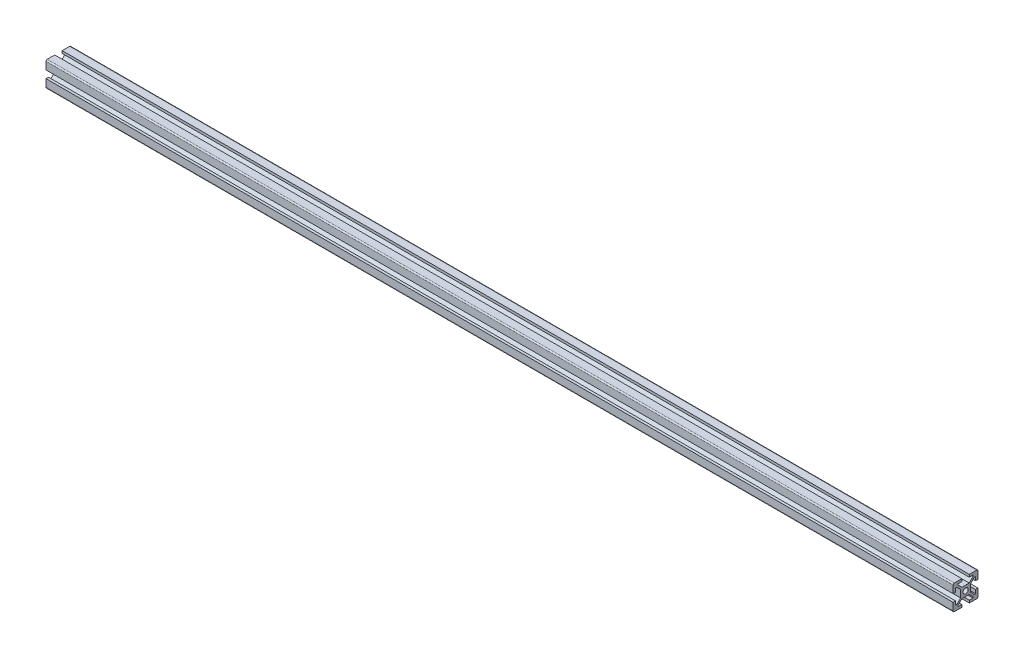
from build123d import *

# Parameters (mm, degrees)
SKETCH1_R           = 2.1
BOSS_EXTRUDE1_DEPTH = 730


with BuildPart() as part:
    # Sketch1 → Boss-Extrude1 (new body)
    with BuildSketch(Plane(origin=(0, 0, 0), x_dir=(0, 0, -1), z_dir=(1, 0, 0))):
        with BuildLine():
            Line((-10, 9), (-10, 3))
            Line((-10, 3), (-8, 3))
            Line((-8, 3), (-8, 6))
            Line((-8, 6), (-7.060660172, 6))
            Line((-7.060660172, 6), (-4, 2.939339828))
            Line((-4, 2.939339828), (-4, -2.939339828))
            Line((-4, -2.939339828), (-7.060660172, -6))
            Line((-7.060660172, -6), (-8, -6))
            Line((-8, -6), (-8, -3))
            Line((-8, -3), (-10, -3))
            Line((-10, -3), (-10, -9))
            ThreePointArc((-10, -9), (-9.707106781, -9.707106781), (-9, -10))
            Line((-9, -10), (-3, -10))
            Line((-3, -10), (-3, -8))
            Line((-3, -8), (-6, -8))
            Line((-6, -8), (-6, -7.060660172))
            Line((-6, -7.060660172), (-2.939339828, -4))
            Line((-2.939339828, -4), (2.939339828, -4))
            Line((2.939339828, -4), (6, -7.060660172))
            Line((6, -7.060660172), (6, -8))
            Line((6, -8), (3, -8))
            Line((3, -8), (3, -10))
            Line((3, -10), (9, -10))
            ThreePointArc((9, -10), (9.707106781, -9.707106781), (10, -9))
            Line((10, -9), (10, -3))
            Line((10, -3), (8, -3))
            Line((8, -3), (8, -6))
            Line((8, -6), (7.060660172, -6))
            Line((7.060660172, -6), (4, -2.939339828))
            Line((4, -2.939339828), (4, 2.939339828))
            Line((4, 2.939339828), (7.060660172, 6))
            Line((7.060660172, 6), (8, 6))
            Line((8, 6), (8, 3))
            Line((8, 3), (10, 3))
            Line((10, 3), (10, 9))
            ThreePointArc((10, 9), (9.707106781, 9.707106781), (9, 10))
            Line((9, 10), (3, 10))
            Line((3, 10), (3, 8))
            Line((3, 8), (6, 8))
            Line((6, 8), (6, 7.060660172))
            Line((6, 7.060660172), (2.939339828, 4))
            Line((2.939339828, 4), (-2.939339828, 4))
            Line((-2.939339828, 4), (-6, 7.060660172))
            Line((-6, 7.060660172), (-6, 8))
            Line((-6, 8), (-3, 8))
            Line((-3, 8), (-3, 10))
            Line((-3, 10), (-9, 10))
            ThreePointArc((-9, 10), (-9.707106781, 9.707106781), (-10, 9))
        make_face()
        Circle(SKETCH1_R, mode=Mode.SUBTRACT)
    extrude(amount=BOSS_EXTRUDE1_DEPTH)


solid = part.part
